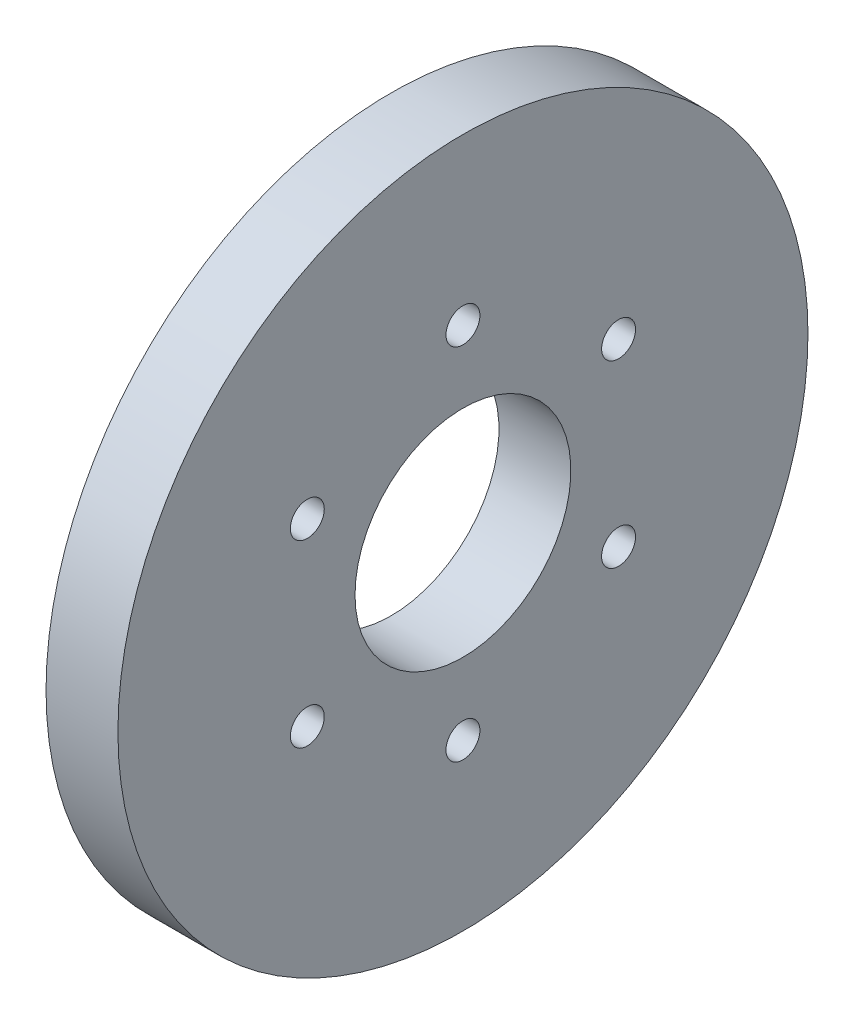
from build123d import *

# Parameters (mm, degrees)
SKETCH1_R             = 45.72
BOSS_EXTRUDE1_DEPTH   = 9.525
SKETCH2_R             = 14.3002
CUT_EXTRUDE1_DEPTH    = 10.525
F_8_CLEARANCE_HOLE1_D = 4.4958
CIRPATTERN1_COUNT     = 6


with BuildPart() as part:
    # Sketch1 → Boss-Extrude1 (new body)
    with BuildSketch(Plane(origin=(0, 0, 0), x_dir=(0, 0, -1), z_dir=(1, 0, 0))):
        Circle(SKETCH1_R)
    extrude(amount=BOSS_EXTRUDE1_DEPTH)

    # Sketch2 → Cut-Extrude1 (cut, through all)
    with BuildSketch(Plane.ZY):
        Circle(SKETCH2_R)
    extrude(amount=-CUT_EXTRUDE1_DEPTH, mode=Mode.SUBTRACT)

    # #8 Clearance Hole1 (through all)
    with Locations(Plane.ZY):
        with Locations((0, 23.8125)):
            f_8_clearance_hole1 = Hole(F_8_CLEARANCE_HOLE1_D / 2)

    # CirPattern1: #8 Clearance Hole1 ×6 about axis
    cirpattern1_axis = Axis((0, 0, 0), (1, 0, 0))
    for i in range(1, CIRPATTERN1_COUNT):
        add(f_8_clearance_hole1.rotate(cirpattern1_axis, i * 360 / CIRPATTERN1_COUNT), mode=Mode.SUBTRACT)


solid = part.part
